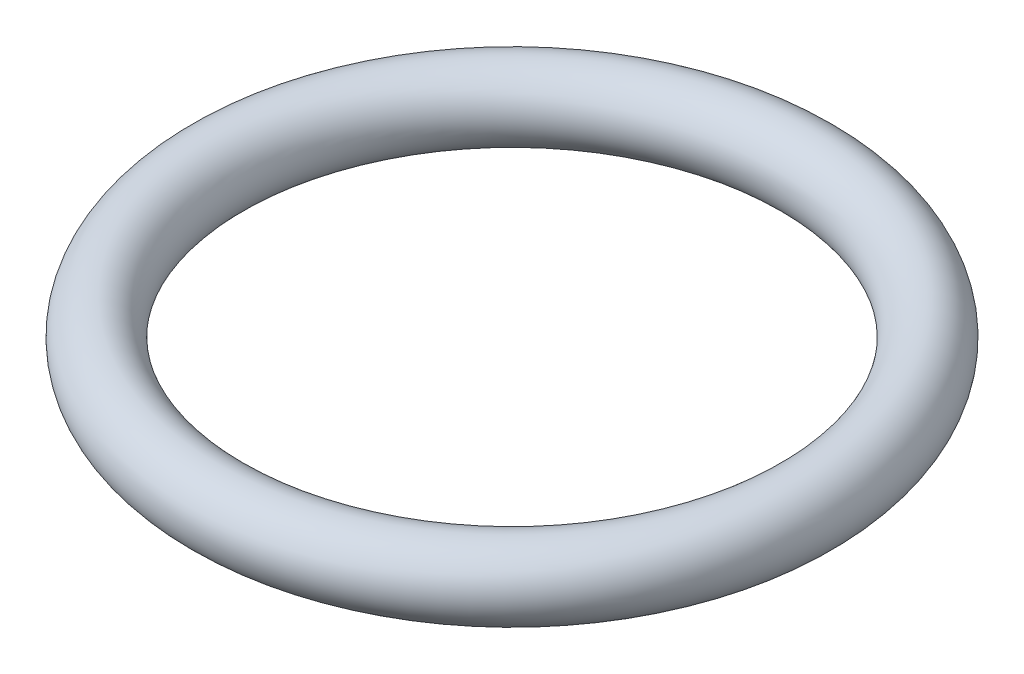
from build123d import *

# Parameters (mm, degrees)
SKETCH1_R = 1


with BuildPart() as part:
    # Sketch1 → Revolve1 (revolve)
    with BuildSketch(Plane.XY):
        with Locations((-8.25, 0)):
            Circle(SKETCH1_R)
    revolve(axis=Axis((0, 3.433256329, 0), (0, -1, 0)))


solid = part.part
